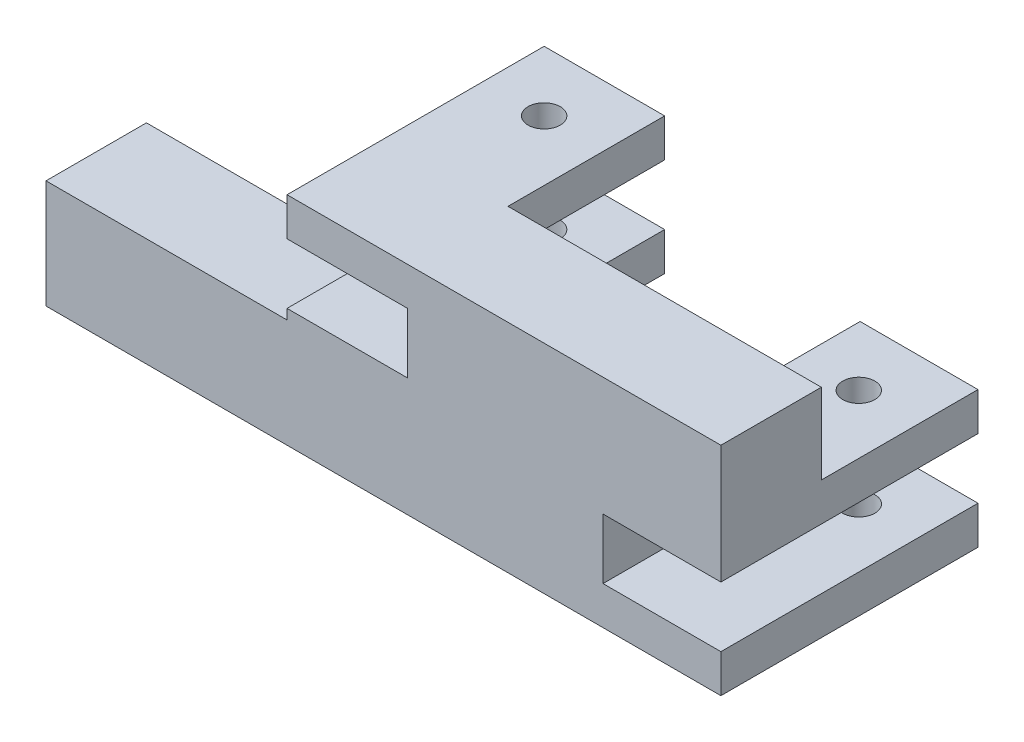
from build123d import *

# Parameters (mm, degrees)
BOSS_EXTRUDE1_DEPTH              = 25
SKETCH4_W                        = 29.345301095
SKETCH4_H                        = 9.5
SKETCH4_W_2                      = 30
BOSS_EXTRUDE2_DEPTH              = 39
SKETCH2_R                        = 4
ACTUATOR_SHAFT_PASSTHROUGH_DEPTH = 54.5
SKETCH7_W                        = 25
SKETCH7_H                        = 27
BOSS_EXTRUDE4_DEPTH              = 60


with BuildPart() as part:
    # Sketch1 → Boss-Extrude1 (new body)
    with BuildSketch(Plane.XY):
        Polygon((-54, 27), (54, 27), (54, -2.5), (24.654698905, -2.5), (24.654698905, -17.5), (54, -17.5), (54, -27), (-54, -27), (-54, 2.5), (-24, 2.5), (-24, 17.5), (-54, 17.5), align=None)
    extrude(amount=BOSS_EXTRUDE1_DEPTH)

    # Sketch4 → Boss-Extrude2 (add)
    with BuildSketch(Plane(origin=(0, 0, 0), x_dir=(-1, 0, 0), z_dir=(0, 0, -1))):
        with Locations((-39.327349453, 2.25)):
            Rectangle(SKETCH4_W, SKETCH4_H)
        with Locations((-39.327349453, -22.25)):
            Rectangle(SKETCH4_W, SKETCH4_H)
        with Locations((39, -2.25)):
            Rectangle(SKETCH4_W_2, SKETCH4_H)
        with Locations((39, 22.25)):
            Rectangle(SKETCH4_W_2, SKETCH4_H)
    extrude(amount=BOSS_EXTRUDE2_DEPTH)

    # Sketch2 → Actuator Shaft Passthrough (cut)
    with BuildSketch(Plane(origin=(0, 27, 0), x_dir=(1, 0, 0), z_dir=(0, 1, 0))):
        with Locations((39.327349452, 24)):
            Circle(SKETCH2_R)
        with Locations((-39, 24)):
            Circle(SKETCH2_R)
    extrude(amount=-ACTUATOR_SHAFT_PASSTHROUGH_DEPTH, mode=Mode.SUBTRACT)

    # Sketch7 → Boss-Extrude4 (add)
    with BuildSketch(Plane.ZY.offset(54)):
        with Locations((12.5, -13.5)):
            Rectangle(SKETCH7_W, SKETCH7_H)
    extrude(amount=BOSS_EXTRUDE4_DEPTH)


solid = part.part
